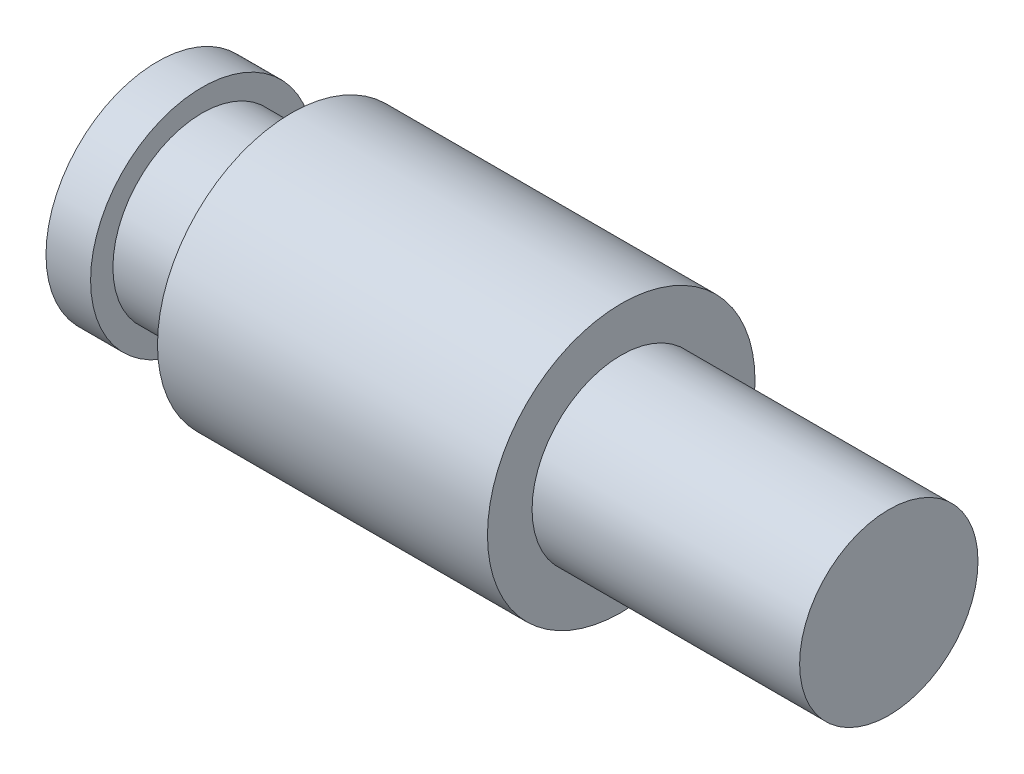
from build123d import *


with BuildPart() as part:
    # Esquisse1 → Révolution1 (revolve)
    with BuildSketch(Plane.XY):
        Polygon((0, 0), (0, 2.5), (1, 2.5), (1, 2), (3, 2), (3, 3), (10.4, 3), (10.4, 2), (16.4, 2), (16.4, 0), align=None)
    revolve(axis=Axis((16.4, 0, 0), (-1, 0, 0)))


solid = part.part
